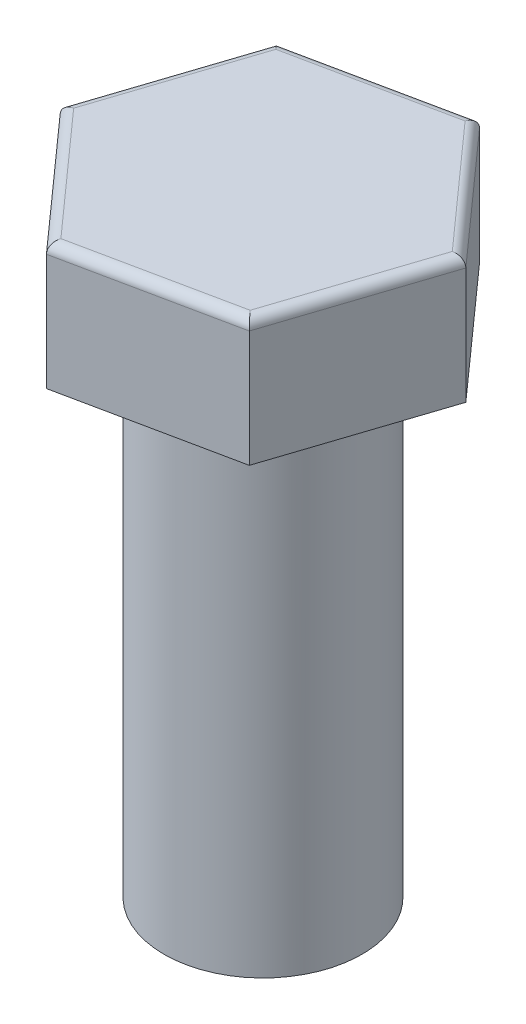
from build123d import *

# Parameters (mm, degrees)
EXTRUDE_1_DEPTH = 7.65
SKETCH_2_R      = 6
EXTRUDE_2_DEPTH = 30
FILLET_1_R      = 0.6


with BuildPart() as part:
    # 草图1 → 凸台-拉伸1 (new body)
    with BuildSketch(Plane(origin=(0, 0, 0), x_dir=(1, 0, 0), z_dir=(0, 1, 0))):
        Polygon((6.921438907, -7.752011575), (10.174158408, 2.118136136), (3.252719501, 9.870147711), (-6.921438907, 7.752011575), (-10.174158408, -2.118136136), (-3.252719501, -9.870147711), align=None)
    extrude(amount=EXTRUDE_1_DEPTH)

    # 草图2 → 凸台-拉伸2 (add)
    with BuildSketch(Plane.XZ):
        Circle(SKETCH_2_R)
    extrude(amount=EXTRUDE_2_DEPTH)

    # 圆角1
    fillet_1_edges = [part.edges().sort_by_distance(p)[0] for p in [
        (6.713438955, 7.65, -5.994141924),
        (-1.834359703, 7.65, -8.811079643),
        (-8.547798657, 7.65, -2.81693772),
        (-6.713438955, 7.65, 5.994141924),
        (1.834359703, 7.65, 8.811079643),
        (8.547798657, 7.65, 2.81693772),
    ]]
    fillet(fillet_1_edges, radius=FILLET_1_R)


solid = part.part
